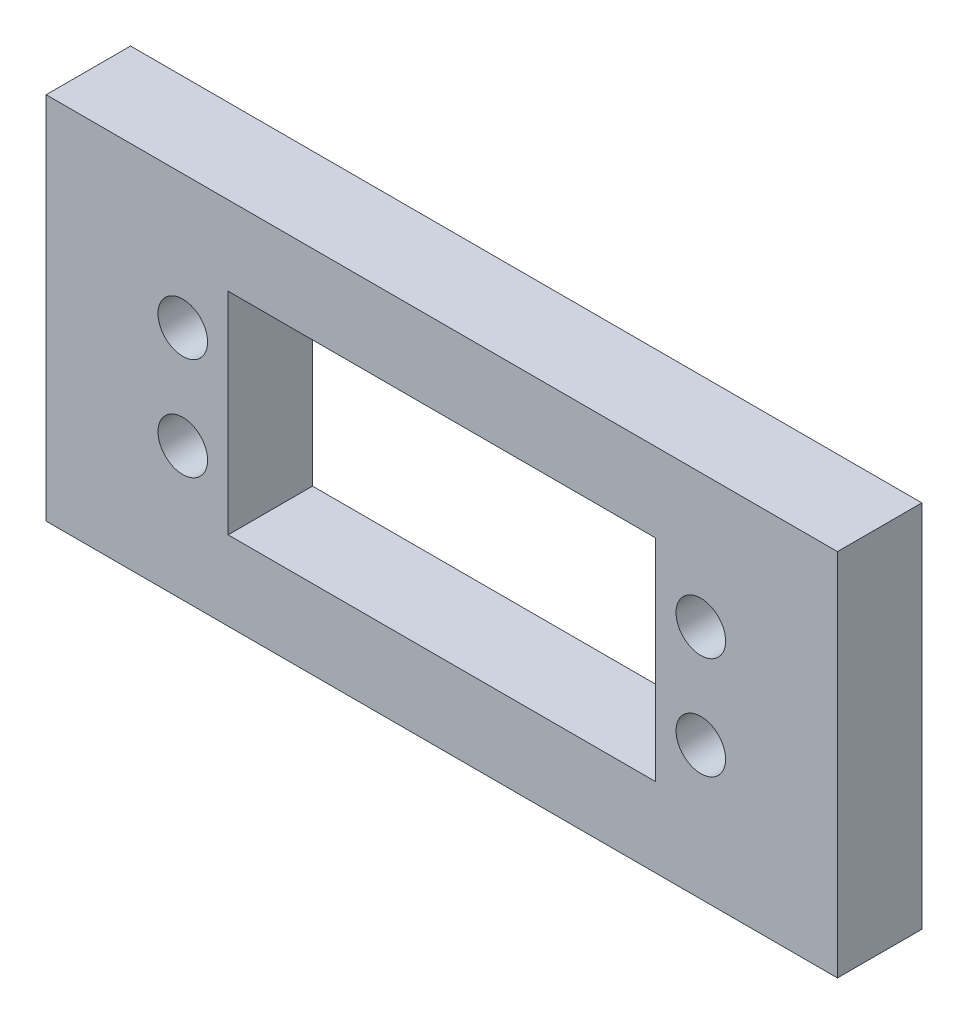
from build123d import *

# Parameters (mm, degrees)
SKETCH2_W           = 104
SKETCH2_H           = 66
BOSS_EXTRUDE1_DEPTH = 8
BOSS_EXTRUDE2_DEPTH = 8
SKETCH4_W           = 104
SKETCH4_H           = 10
CUT_EXTRUDE1_DEPTH  = 8
BOSS_EXTRUDE4_DEPTH = 8
CUT_EXTRUDE2_DEPTH  = 8
SKETCH9_R           = 2.5
CUT_EXTRUDE3_DEPTH  = 9
CUT_EXTRUDE4_REACH  = 10
SKETCH10_R          = 2.35
SKETCH10_W          = 40.5
SKETCH10_H          = 20
CUT_EXTRUDE5_REACH  = 10
SKETCH11_W          = 128
SKETCH11_H          = 82


with BuildPart() as part:
    # Sketch2 → Boss-Extrude1 (new body)
    with BuildSketch(Plane.XY):
        Rectangle(SKETCH2_W, SKETCH2_H)
    extrude(amount=BOSS_EXTRUDE1_DEPTH)

    # Sketch3 → Boss-Extrude2 (add, through all)
    with BuildSketch(Plane.XY.offset(8)):
        Polygon((-52, -17), (-60, -17), (-60, -22), (-64, -22), (-64, -2), (-60, -2), (-60, -7), (-52, -7), align=None)
        Polygon((-52, 13), (-60, 13), (-60, 8), (-64, 8), (-64, 28), (-60, 28), (-60, 23), (-52, 23), align=None)
        Polygon((52, -7), (52, -17), (60, -17), (60, -22), (64, -22), (64, -2), (60, -2), (60, -7), align=None)
        Polygon((-32.5, -33), (-32.5, -41), (-37.5, -41), (-37.5, -76), (37.5, -76), (37.5, -41), (32.5, -41), (32.5, -33), (17.5, -33), (17.5, -41), (-17.5, -41), (-17.5, -33), align=None)
    extrude(amount=-BOSS_EXTRUDE2_DEPTH)

    # Sketch4 → Cut-Extrude1 (cut)
    with BuildSketch(Plane.XY.offset(8)):
        with Locations((0, 28)):
            Rectangle(SKETCH4_W, SKETCH4_H)
    extrude(amount=-CUT_EXTRUDE1_DEPTH, mode=Mode.SUBTRACT)

    # Sketch6 → Boss-Extrude4 (add)
    with BuildSketch(Plane.XY.offset(8)):
        with BuildLine():
            Line((52, 17), (52, 0))
            Line((52, 0), (0, 0))
            Line((0, 0), (0, 23))
            Line((0, 23), (42, 23))
            ThreePointArc((42, 23), (57.458350242, 37.430583736), (52, 17))
        make_face()
    extrude(amount=-BOSS_EXTRUDE4_DEPTH)

    # Sketch8 → Cut-Extrude2 (cut)
    with BuildSketch(Plane.XY.offset(8)):
        with BuildLine():
            Line((47.287664075, 17.965775092), (41.287664075, 7.573470247))
            ThreePointArc((41.287664075, 7.573470247), (46.489081435, 5.649562257), (52, 5.028320703))
            Line((52, 5.028320703), (52, 17))
            ThreePointArc((52, 17), (49.590394027, 17.222145828), (47.287664075, 17.965775092))
        make_face()
    extrude(amount=-CUT_EXTRUDE2_DEPTH, mode=Mode.SUBTRACT)

    # Sketch9 → Cut-Extrude3 (cut, through all)
    with BuildSketch(Plane.XY.offset(8)):
        with Locations((51.798896932, 27.998161553)):
            Circle(SKETCH9_R)
    extrude(amount=-CUT_EXTRUDE3_DEPTH, mode=Mode.SUBTRACT)

    # Sketch10 → Cut-Extrude4 (cut, up to next)
    with BuildSketch(Plane.XY.offset(8), mode=Mode.PRIVATE) as cut_extrude4_sk1:
        with Locations((-24.55, -53.65)):
            Circle(SKETCH10_R)
    cut_extrude4_tool1 = extrude(cut_extrude4_sk1.sketch, amount=-CUT_EXTRUDE4_REACH, mode=Mode.PRIVATE) & part.part
    add(cut_extrude4_tool1.solids().sort_by_distance((-24.55, -53.65, 8))[0], mode=Mode.SUBTRACT)
    # Sketch10 → Cut-Extrude4 (cut, up to next)
    with BuildSketch(Plane.XY.offset(8), mode=Mode.PRIVATE) as cut_extrude4_sk2:
        with Locations((-24.55, -63.35)):
            Circle(SKETCH10_R)
    cut_extrude4_tool2 = extrude(cut_extrude4_sk2.sketch, amount=-CUT_EXTRUDE4_REACH, mode=Mode.PRIVATE) & part.part
    add(cut_extrude4_tool2.solids().sort_by_distance((-24.55, -63.35, 8))[0], mode=Mode.SUBTRACT)
    # Sketch10 → Cut-Extrude4 (cut, up to next)
    with BuildSketch(Plane.XY.offset(8), mode=Mode.PRIVATE) as cut_extrude4_sk3:
        with Locations((24.55, -63.35)):
            Circle(SKETCH10_R)
    cut_extrude4_tool3 = extrude(cut_extrude4_sk3.sketch, amount=-CUT_EXTRUDE4_REACH, mode=Mode.PRIVATE) & part.part
    add(cut_extrude4_tool3.solids().sort_by_distance((24.55, -63.35, 8))[0], mode=Mode.SUBTRACT)
    # Sketch10 → Cut-Extrude4 (cut, up to next)
    with BuildSketch(Plane.XY.offset(8), mode=Mode.PRIVATE) as cut_extrude4_sk4:
        with Locations((24.55, -53.65)):
            Circle(SKETCH10_R)
    cut_extrude4_tool4 = extrude(cut_extrude4_sk4.sketch, amount=-CUT_EXTRUDE4_REACH, mode=Mode.PRIVATE) & part.part
    add(cut_extrude4_tool4.solids().sort_by_distance((24.55, -53.65, 8))[0], mode=Mode.SUBTRACT)
    # Sketch10 → Cut-Extrude4 (cut, up to next)
    with BuildSketch(Plane.XY.offset(8), mode=Mode.PRIVATE) as cut_extrude4_sk5:
        with Locations((0, -58.5)):
            Rectangle(SKETCH10_W, SKETCH10_H)
    cut_extrude4_tool5 = extrude(cut_extrude4_sk5.sketch, amount=-CUT_EXTRUDE4_REACH, mode=Mode.PRIVATE) & part.part
    add(cut_extrude4_tool5.solids().sort_by_distance((0, -58.5, 8))[0], mode=Mode.SUBTRACT)

    # Sketch11 → Cut-Extrude5 (cut, up to next)
    with BuildSketch(Plane.XY.offset(8), mode=Mode.PRIVATE) as cut_extrude5_sk1:
        Rectangle(SKETCH11_W, SKETCH11_H)
    cut_extrude5_tool1 = extrude(cut_extrude5_sk1.sketch, amount=-CUT_EXTRUDE5_REACH, mode=Mode.PRIVATE) & part.part
    add(cut_extrude5_tool1.solids().sort_by_distance((0, 0, 8))[0], mode=Mode.SUBTRACT)


solid = part.part
